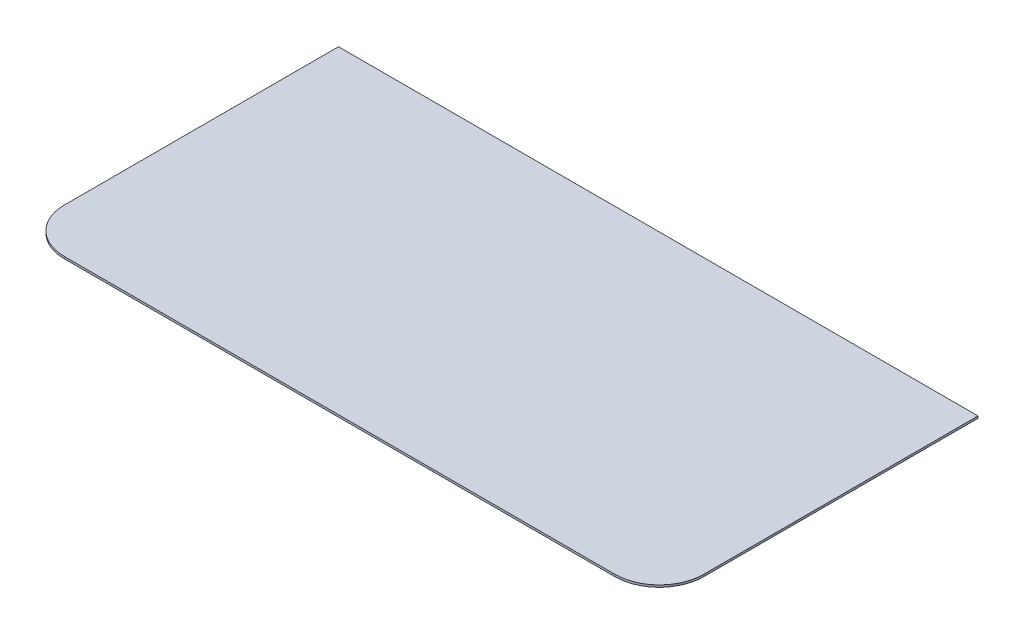
from build123d import *

# Parameters (mm, degrees)
SKIZZE1_W                  = 151
SKIZZE1_H                  = 150.5
LINEAR_AUSTRAGEN1_DEPTH    = 1
VERRUNDUNG1_R              = 21
VERRUNDUNG1_OF_SPIEGELN1_R = 21


with BuildPart() as part:
    # Skizze1 → Linear austragen1 (new body)
    with BuildSketch(Plane(origin=(0, 0, 0), x_dir=(1, 0, 0), z_dir=(0, 1, 0))):
        with Locations((75.5, 75.25)):
            Rectangle(SKIZZE1_W, SKIZZE1_H)
    linear_austragen1 = extrude(amount=LINEAR_AUSTRAGEN1_DEPTH)

    # Verrundung1
    verrundung1_edges = [part.edges().sort_by_distance(p)[0] for p in [
        (151, 0.5, 0),
    ]]
    fillet(verrundung1_edges, radius=VERRUNDUNG1_R)

    # Spiegeln1: Linear austragen1 across plane
    add(linear_austragen1.mirror(Plane(origin=(0, 1, 0), x_dir=(0, 0, 1), z_dir=(1, 0, 0))))

    # Verrundung1 of Spiegeln1
    verrundung1_of_spiegeln1_edges = [part.edges().sort_by_distance(p)[0] for p in [
        (-151, 0.5, 0),
    ]]
    fillet(verrundung1_of_spiegeln1_edges, radius=VERRUNDUNG1_OF_SPIEGELN1_R)


solid = part.part
